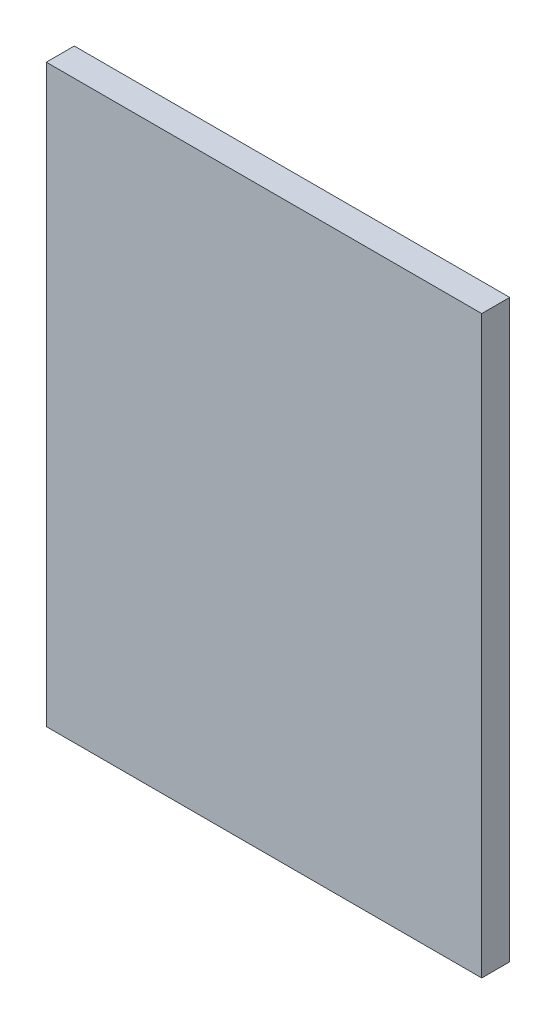
from build123d import *

# Parameters (mm, degrees)
SKETCH1_W           = 280
SKETCH1_H           = 370
BOSS_EXTRUDE1_DEPTH = 18


with BuildPart() as part:
    # Sketch1 → Boss-Extrude1 (new body)
    with BuildSketch(Plane.XY):
        Rectangle(SKETCH1_W, SKETCH1_H)
    extrude(amount=BOSS_EXTRUDE1_DEPTH)


solid = part.part
